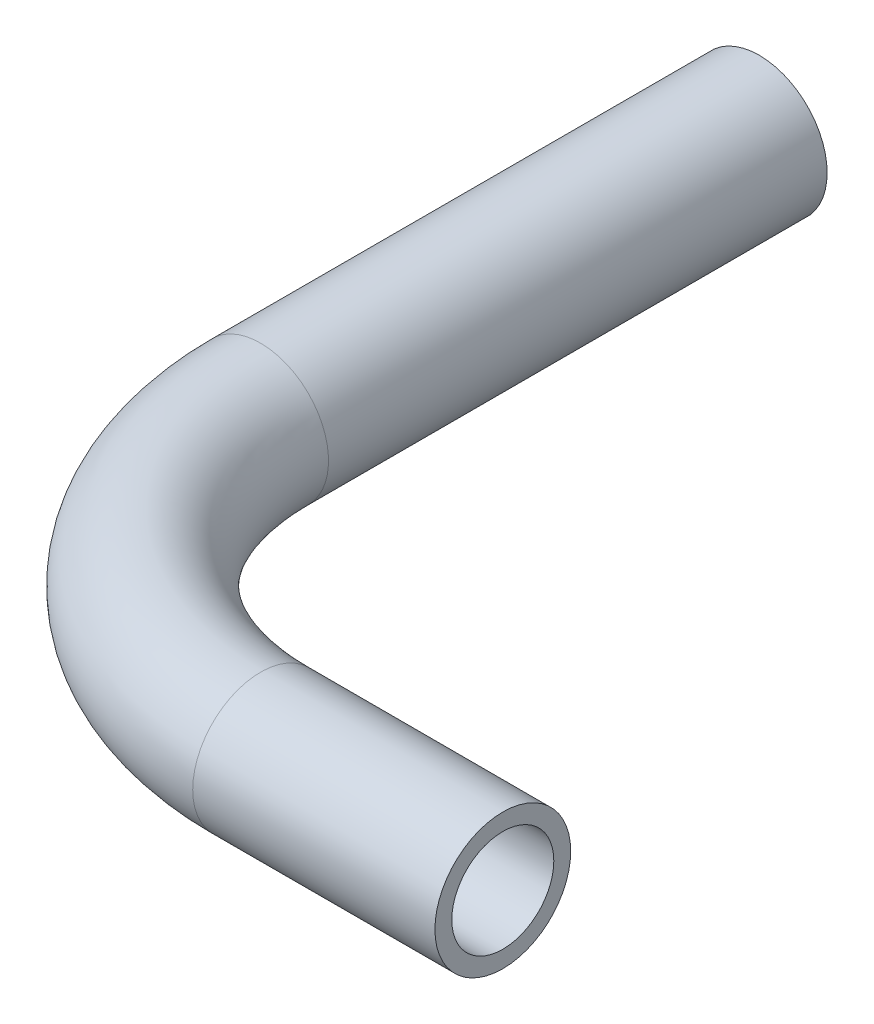
from build123d import *

# Parameters (mm, degrees)
SKETCH_1_R   = 4.765
SKETCH_1_R_2 = 3.58


with BuildPart() as part:
    # По траектории1: sweep along a curve in space
    with BuildLine() as sweep_1_path:
        Line((0, 0, 0), (0, 0, 35))
        ThreePointArc((0, 0, 35), (5.857864376, 0, 49.142135624), (20, 0, 55))
        Line((20, 0, 55), (37, 0, 55))
    # Эскиз1 → По траектории1 (sweep)
    with BuildSketch(Plane.XY):
        Circle(SKETCH_1_R)
        Circle(SKETCH_1_R_2, mode=Mode.SUBTRACT)
    sweep(path=sweep_1_path.line)


solid = part.part
